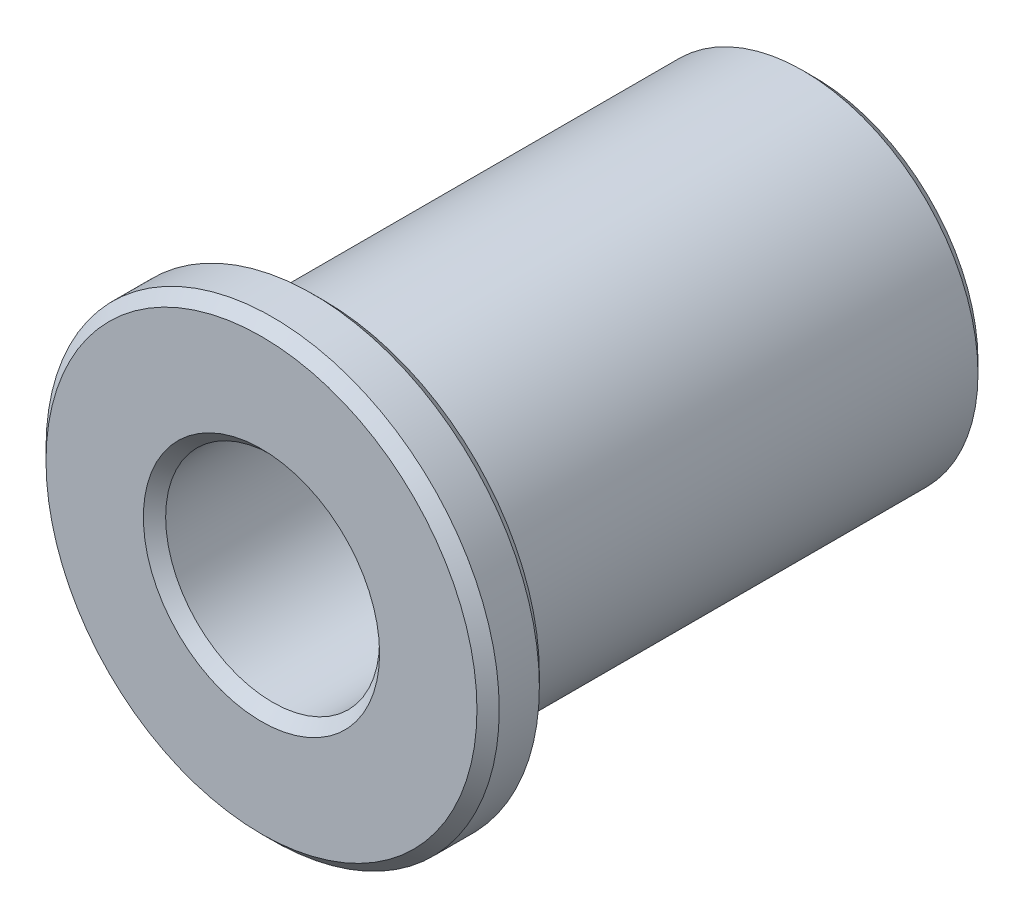
from build123d import *

# Parameters (mm, degrees)
SKETCH1_R           = 3.925
BOSS_EXTRUDE1_DEPTH = 11
SKETCH2_R           = 5.084149635
BOSS_EXTRUDE2_DEPTH = 1.4
SKETCH3_R           = 2.4
CUT_EXTRUDE1_DEPTH  = 13.4
CHAMFER1_SIZE       = 0.25


with BuildPart() as part:
    # Sketch1 → Boss-Extrude1 (new body)
    with BuildSketch(Plane.XY):
        Circle(SKETCH1_R)
    extrude(amount=-BOSS_EXTRUDE1_DEPTH)

    # Sketch2 → Boss-Extrude2 (add)
    with BuildSketch(Plane.XY):
        Circle(SKETCH2_R)
    extrude(amount=BOSS_EXTRUDE2_DEPTH)

    # Sketch3 → Cut-Extrude1 (cut, through all)
    with BuildSketch(Plane.XY.offset(1.4)):
        Circle(SKETCH3_R)
    extrude(amount=-CUT_EXTRUDE1_DEPTH, mode=Mode.SUBTRACT)

    # Chamfer1
    chamfer1_edges = [part.edges().sort_by_distance(p)[0] for p in [
        (-2.4, 0, -11),
        (-2.4, 0, 1.4),
        (-3.925, 0, -11),
        (-5.084149635, 0, 0),
        (-5.084149635, 0, 1.4),
    ]]
    chamfer(chamfer1_edges, length=CHAMFER1_SIZE)


solid = part.part
